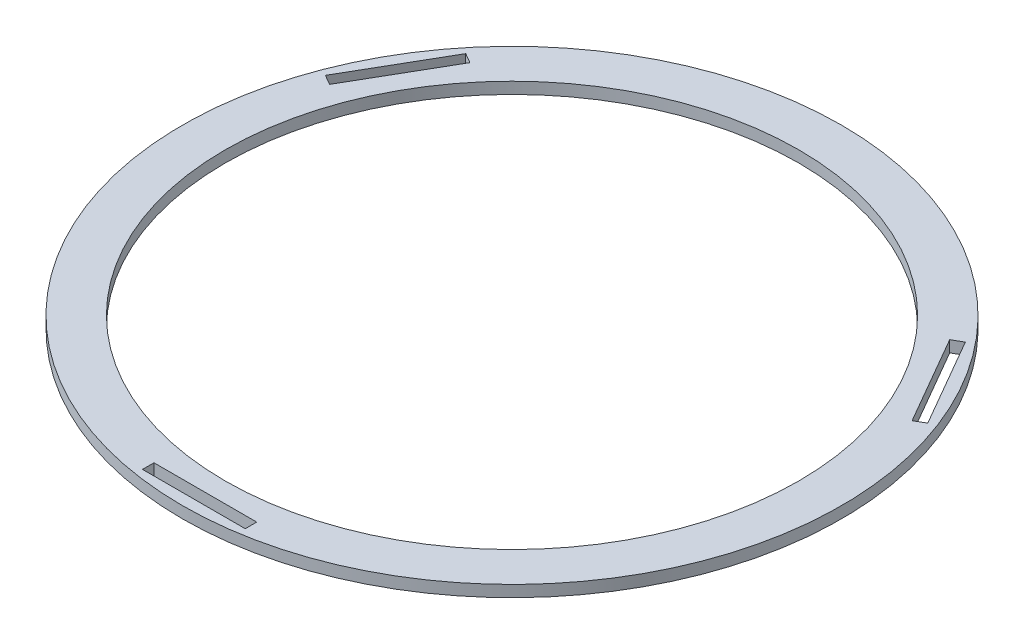
from build123d import *

# Parameters (mm, degrees)
SKETCH1_R           = 287.263450512
SKETCH1_R_2         = 250
BOSS_EXTRUDE1_DEPTH = 10
SKETCH2_W           = 89.558863324
SKETCH2_H           = 10
CUT_EXTRUDE1_DEPTH  = 10
CIRPATTERN1_COUNT   = 3


with BuildPart() as part:
    # Sketch1 → Boss-Extrude1 (new body)
    with BuildSketch(Plane(origin=(0, 0, 0), x_dir=(1, 0, 0), z_dir=(0, 1, 0))):
        Circle(SKETCH1_R)
        Circle(SKETCH1_R_2, mode=Mode.SUBTRACT)
    extrude(amount=BOSS_EXTRUDE1_DEPTH)

    # Sketch2 → Cut-Extrude1 (cut)
    with BuildSketch(Plane(origin=(0, 10, 0), x_dir=(1, 0, 0), z_dir=(0, 1, 0))):
        with Locations((0, -272.3)):
            Rectangle(SKETCH2_W, SKETCH2_H)
    cut_extrude1 = extrude(amount=-CUT_EXTRUDE1_DEPTH, mode=Mode.SUBTRACT)

    # CirPattern1: Cut-Extrude1 ×3 about axis
    cirpattern1_axis = Axis((0, 0, 0), (0, 1, 0))
    for i in range(1, CIRPATTERN1_COUNT):
        add(cut_extrude1.rotate(cirpattern1_axis, i * 360 / CIRPATTERN1_COUNT), mode=Mode.SUBTRACT)


solid = part.part
